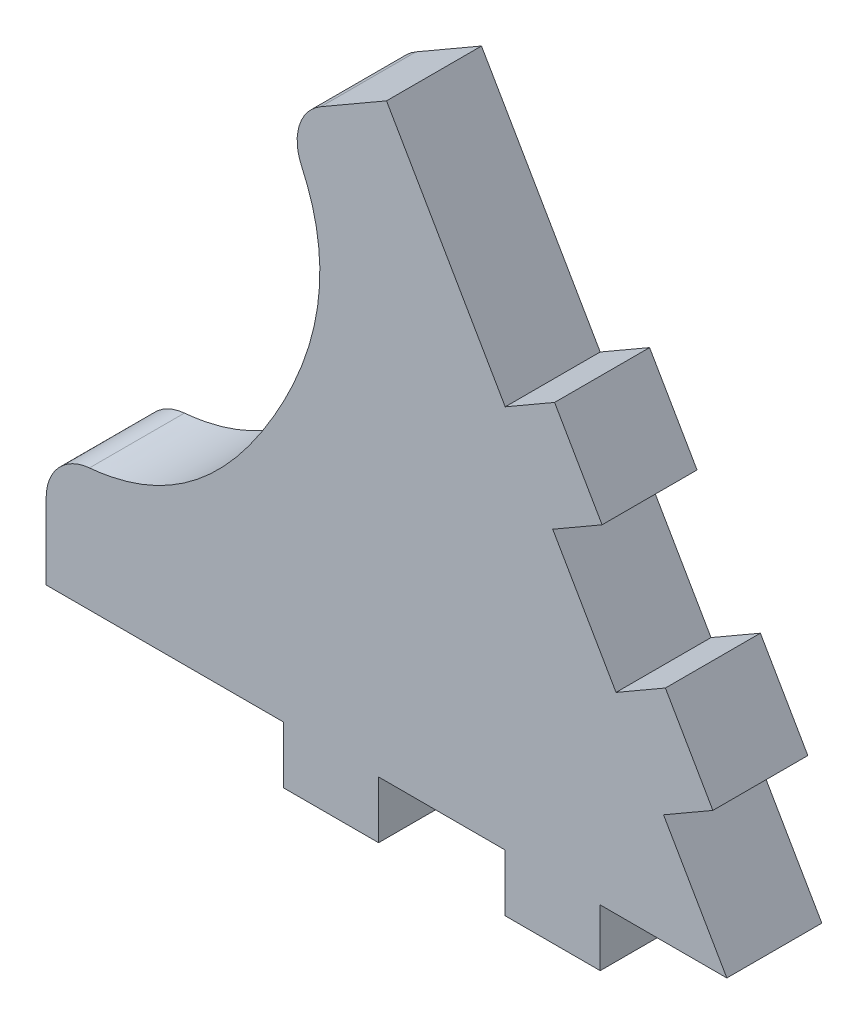
from build123d import *

# Parameters (mm, degrees)
BOSS_EXTRUDE1_DEPTH = 10
FILLET1_R           = 5


with BuildPart() as part:
    # Sketch1 → Boss-Extrude1 (new body)
    with BuildSketch(Plane.XY):
        with BuildLine():
            Line((36.66666666, -6), (36.66666666, 0))
            Line((36.66666666, 0), (23.33333333, 0))
            Line((23.33333333, 0), (23.33333333, -6))
            Line((23.33333333, -6), (13.33333333, -6))
            Line((13.33333333, -6), (13.33333333, 0))
            Line((13.33333333, 0), (-11.66666667, 0))
            Line((-11.66666667, 0), (-11.66666667, 13))
            add(Edge.make_bspline(
                [(-11.66666667, 13), (-1.66449563, 11.980359681), (6.23568211, 16.877469798), (12.368602782, 27.5)],
                knots=[0, 0, 0, 0, 1, 1, 1, 1], degree=3))
            add(Edge.make_bspline(
                [(12.908336411, 55.565153932), (18.792456349, 47.412839878), (18.501523453, 38.122530202), (12.368602782, 27.5)],
                knots=[0, 0, 0, 0, 1, 1, 1, 1], degree=3))
            Line((12.908336411, 55.565153932), (24.16666666, 62.065153932))
            Line((24.16666666, 62.065153932), (36.66666666, 40.414518838))
            Line((36.66666666, 40.414518838), (41.862819083, 43.414518838))
            Line((41.862819083, 43.414518838), (46.862819083, 34.7542648))
            Line((46.862819083, 34.7542648), (41.66666666, 31.7542648))
            Line((41.66666666, 31.7542648), (48.333333325, 20.207259419))
            Line((48.333333325, 20.207259419), (53.529485748, 23.207259419))
            Line((53.529485748, 23.207259419), (58.529485748, 14.547005381))
            Line((58.529485748, 14.547005381), (53.333333325, 11.547005381))
            Line((53.333333325, 11.547005381), (59.99999999, 0))
            Line((59.99999999, 0), (46.66666666, 0))
            Line((46.66666666, 0), (46.66666666, -6))
            Line((46.66666666, -6), (36.66666666, -6))
        make_face()
    extrude(amount=BOSS_EXTRUDE1_DEPTH)

    # Fillet1
    fillet1_edges = [part.edges().sort_by_distance(p)[0] for p in [
        (-11.66666667, 13, 5),
        (12.908336411, 55.565153932, 5),
    ]]
    fillet(fillet1_edges, radius=FILLET1_R)


solid = part.part
